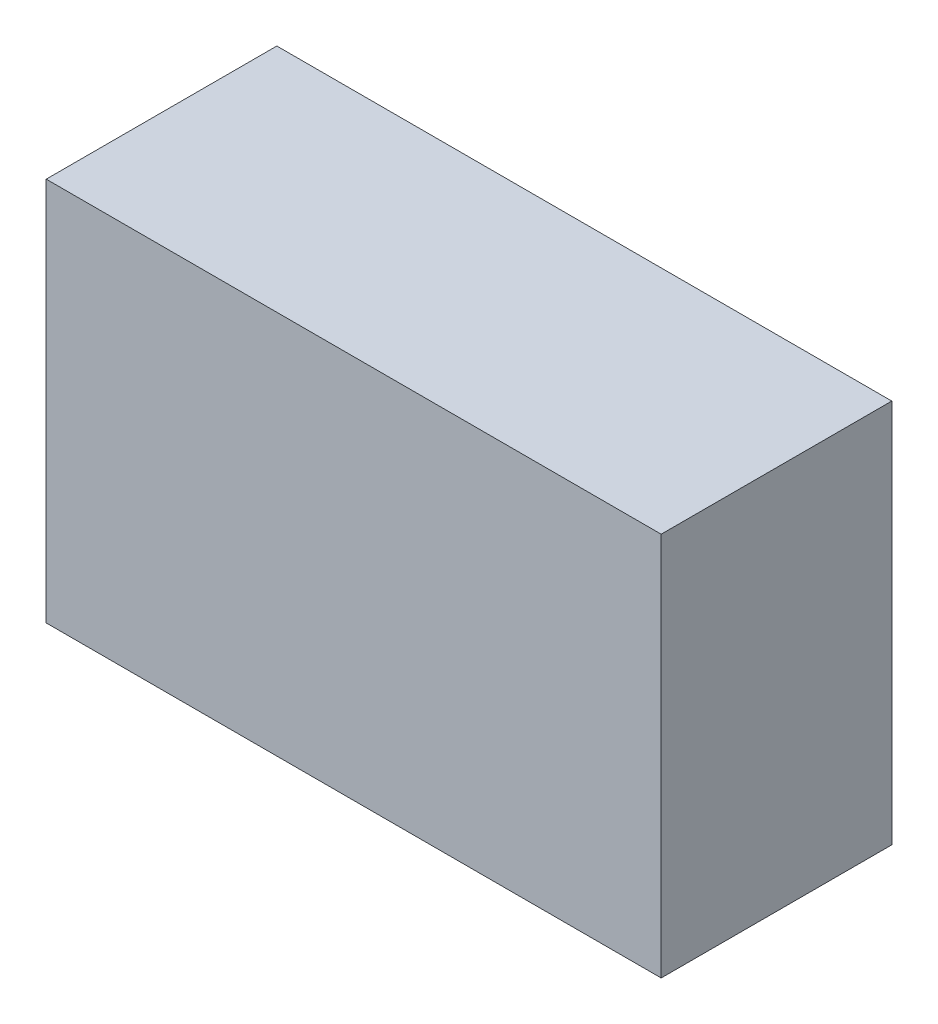
from build123d import *

# Parameters (mm, degrees)
SKETCH1_W      = 4000
SKETCH1_H      = 2500
EXTRUDE1_DEPTH = 1500


with BuildPart() as part:
    # Sketch1 → Extrude1 (new body)
    with BuildSketch(Plane.XY):
        with Locations((-7050, -1550)):
            Rectangle(SKETCH1_W, SKETCH1_H)
    extrude(amount=EXTRUDE1_DEPTH)


solid = part.part
